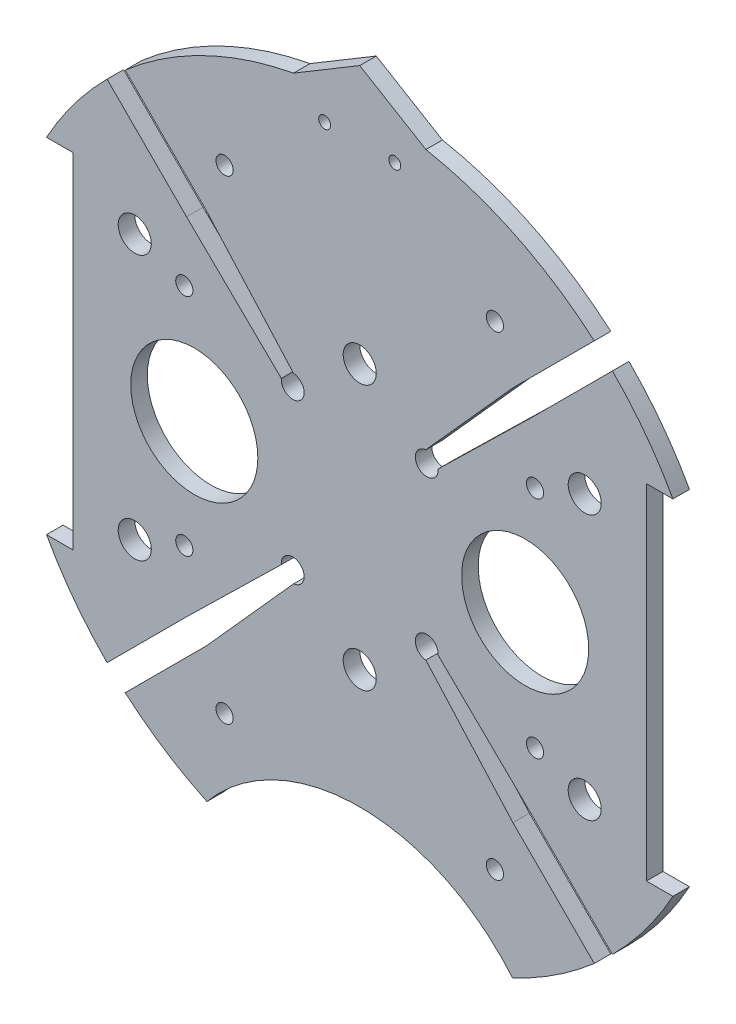
from build123d import *

# Parameters (mm, degrees)
BOSS_EXTRUDE2_DEPTH      = 3.175
SKETCH4_R                = 38.1
CUT_EXTRUDE3_DEPTH       = 92.247975457
CUT_EXTRUDE6_DEPTH       = 92.247975457
BOSS_EXTRUDE3_DEPTH      = 3.175
SKETCH12_R               = 1.143
CUT_EXTRUDE9_DEPTH       = 97.166400707
SKETCH14_R               = 3.175
CUT_EXTRUDE11_DEPTH      = 103.378
CUT_EXTRUDE11_DEPTH_BACK = 116.832157669
SKETCH15_R               = 1.651
CUT_EXTRUDE12_DEPTH      = 75.692
SKETCH17_R               = 1.651
CUT_EXTRUDE14_DEPTH      = 97.79
SKETCH18_R               = 12.192
CUT_EXTRUDE15_DEPTH      = 35.56


with BuildPart() as part:
    # Sketch1 → Boss-Extrude2 (new body)
    with BuildSketch(Plane.XY):
        with BuildLine():
            Line((-60.107370596, 33.02), (-55.027370596, 33.02))
            Line((-55.027370596, 33.02), (-55.027370596, -33.02))
            Line((-55.027370596, -33.02), (-60.107370596, -33.02))
            ThreePointArc((-60.107370596, -33.02), (0, -68.58), (60.107370596, -33.02))
            Line((60.107370596, -33.02), (55.027370596, -33.02))
            Line((55.027370596, -33.02), (55.027370596, 33.02))
            Line((55.027370596, 33.02), (60.107370596, 33.02))
            ThreePointArc((60.107370596, 33.02), (0, 68.58), (-60.107370596, 33.02))
        make_face()
    extrude(amount=BOSS_EXTRUDE2_DEPTH)

    # Sketch4 → Cut-Extrude3 (cut, through all)
    with BuildSketch(Plane(origin=(0, 0, 0), x_dir=(-1, 0, 0), z_dir=(0, 0, -1))):
        with Locations((0, -86.312058398)):
            Circle(SKETCH4_R)
    extrude(amount=-CUT_EXTRUDE3_DEPTH, mode=Mode.SUBTRACT)

    # Sketch5 → Cut-Extrude6 (cut, through all)
    with BuildSketch(Plane(origin=(0, 0, 0), x_dir=(-1, 0, 0), z_dir=(0, 0, -1))):
        with BuildLine():
            ThreePointArc((45.008715274, -51.743907365), (46.779291091, -50.148921474), (48.493383054, -48.493383054))
            Line((48.493383054, -48.493383054), (33.244765274, -33.244765274))
            Line((33.244765274, -33.244765274), (15.050661462, -15.479201839))
            ThreePointArc((15.050661462, -15.479201839), (11.453327097, -13.609958514), (12.680560823, -17.473736785))
            Line((12.680560823, -17.473736785), (29.410338797, -36.145530887))
            Line((29.410338797, -36.145530887), (45.008715274, -51.743907365))
        make_face()
        with BuildLine():
            ThreePointArc((-48.493383054, -48.493383054), (-46.779291091, -50.148921474), (-45.008715274, -51.743907365))
            Line((-45.008715274, -51.743907365), (-29.410338797, -36.145530887))
            Line((-29.410338797, -36.145530887), (-12.680560823, -17.473736785))
            ThreePointArc((-12.680560823, -17.473736785), (-11.453327097, -13.609958514), (-15.050661462, -15.479201839))
            Line((-15.050661462, -15.479201839), (-33.244765274, -33.244765274))
            Line((-33.244765274, -33.244765274), (-48.493383054, -48.493383054))
        make_face()
        with BuildLine():
            Line((-29.410338797, 36.145530887), (-45.008715274, 51.743907365))
            ThreePointArc((-45.008715274, 51.743907365), (-46.779291091, 50.148921474), (-48.493383054, 48.493383054))
            Line((-48.493383054, 48.493383054), (-33.244765274, 33.244765274))
            Line((-33.244765274, 33.244765274), (-15.050661462, 15.479201839))
            ThreePointArc((-15.050661462, 15.479201839), (-11.453327097, 13.609958514), (-12.680560823, 17.473736785))
            Line((-12.680560823, 17.473736785), (-29.410338797, 36.145530887))
        make_face()
        with BuildLine():
            Line((33.244765274, 33.244765274), (48.493383054, 48.493383054))
            ThreePointArc((48.493383054, 48.493383054), (46.779291091, 50.148921474), (45.008715274, 51.743907365))
            Line((45.008715274, 51.743907365), (29.410338797, 36.145530887))
            Line((29.410338797, 36.145530887), (12.680560823, 17.473736785))
            ThreePointArc((12.680560823, 17.473736785), (11.453327097, 13.609958514), (15.050661462, 15.479201839))
            Line((15.050661462, 15.479201839), (33.244765274, 33.244765274))
        make_face()
    extrude(amount=-CUT_EXTRUDE6_DEPTH, mode=Mode.SUBTRACT)

    # Sketch9 → Boss-Extrude3 (add)
    with BuildSketch(Plane(origin=(0, 0, 0), x_dir=(-1, 0, 0), z_dir=(0, 0, -1))):
        with BuildLine():
            Line((12.7, 67.39381574), (0, 75))
            Line((0, 75), (-12.7, 67.39381574))
            ThreePointArc((-12.7, 67.39381574), (0, 68.58), (12.7, 67.39381574))
        make_face()
    extrude(amount=-BOSS_EXTRUDE3_DEPTH)

    # Sketch12 → Cut-Extrude9 (cut, through all)
    with BuildSketch(Plane(origin=(0, 0, 0), x_dir=(-1, 0, 0), z_dir=(0, 0, -1))):
        with Locations((6.731, 62.23)):
            Circle(SKETCH12_R)
        with Locations((-6.731, 62.23)):
            Circle(SKETCH12_R)
    extrude(amount=-CUT_EXTRUDE9_DEPTH, mode=Mode.SUBTRACT)

    # Sketch14 → Cut-Extrude11 (cut, two sides)
    with BuildSketch(Plane(origin=(30.092005081, 4.08352975, 15.875), x_dir=(-1, 0, 0), z_dir=(0, 0, -1))) as cut_extrude11_sk:
        with Locations(Location((-13.087994919, 21.31647025, 0), (0, 0, 180))):
            Circle(SKETCH14_R)
        with Locations(Location((73.272005081, 21.31647025, 0), (0, 0, 180))):
            Circle(SKETCH14_R)
        with Locations(Location((30.092005081, 21.31647025, 0), (0, 0, 180))):
            Circle(SKETCH14_R)
        with Locations(Location((73.272005081, -29.48352975, 0), (0, 0, 180))):
            Circle(SKETCH14_R)
        with Locations(Location((30.092005081, -29.48352975, 0), (0, 0, 180))):
            Circle(SKETCH14_R)
        with Locations(Location((-13.087994919, -29.48352975, 0), (0, 0, 180))):
            Circle(SKETCH14_R)
    extrude(amount=CUT_EXTRUDE11_DEPTH, mode=Mode.SUBTRACT)
    extrude(cut_extrude11_sk.sketch, amount=-CUT_EXTRUDE11_DEPTH_BACK, mode=Mode.SUBTRACT)

    # Sketch15 → Cut-Extrude12 (cut)
    with BuildSketch(Plane(origin=(30.092005081, 4.08352975, -25.527), x_dir=(-1, 0, 0), z_dir=(0, 0, -1))):
        with Locations(Location((63.757223581, 17.50647025, 0), (0, 0, 180))):
            Circle(SKETCH15_R)
        with Locations(Location((63.757223581, -25.67352975, 0), (0, 0, 180))):
            Circle(SKETCH15_R)
        with Locations(Location((-3.552776419, -25.67352975, 0), (0, 0, 180))):
            Circle(SKETCH15_R)
        with Locations(Location((-3.552776419, 17.50647025, 0), (0, 0, 180))):
            Circle(SKETCH15_R)
    extrude(amount=-CUT_EXTRUDE12_DEPTH, mode=Mode.SUBTRACT)

    # Sketch17 → Cut-Extrude14 (cut)
    with BuildSketch(Plane(origin=(30.092005081, 4.08352975, -31.75), x_dir=(-1, 0, 0), z_dir=(0, 0, -1))):
        with Locations(Location((4.154396091, -49.728759131, 0), (0, 0, 180))):
            Circle(SKETCH17_R)
        with Locations(Location((56.02961407, -49.728759131, 0), (0, 0, 180))):
            Circle(SKETCH17_R)
        with Locations(Location((4.154396091, 41.38247025, 0), (0, 0, 180))):
            Circle(SKETCH17_R)
        with Locations(Location((56.02961407, 41.38247025, 0), (0, 0, 180))):
            Circle(SKETCH17_R)
    extrude(amount=-CUT_EXTRUDE14_DEPTH, mode=Mode.SUBTRACT)

    # Sketch18 → Cut-Extrude15 (cut)
    with BuildSketch(Plane(origin=(0, 0, 0), x_dir=(-1, 0, 0), z_dir=(0, 0, -1))):
        with Locations((31.75, 0)):
            Circle(SKETCH18_R)
        with Locations(Location((-31.75, 0, 0), (0, 0, 180))):
            Circle(SKETCH18_R)
    extrude(amount=-CUT_EXTRUDE15_DEPTH, mode=Mode.SUBTRACT)


solid = part.part
